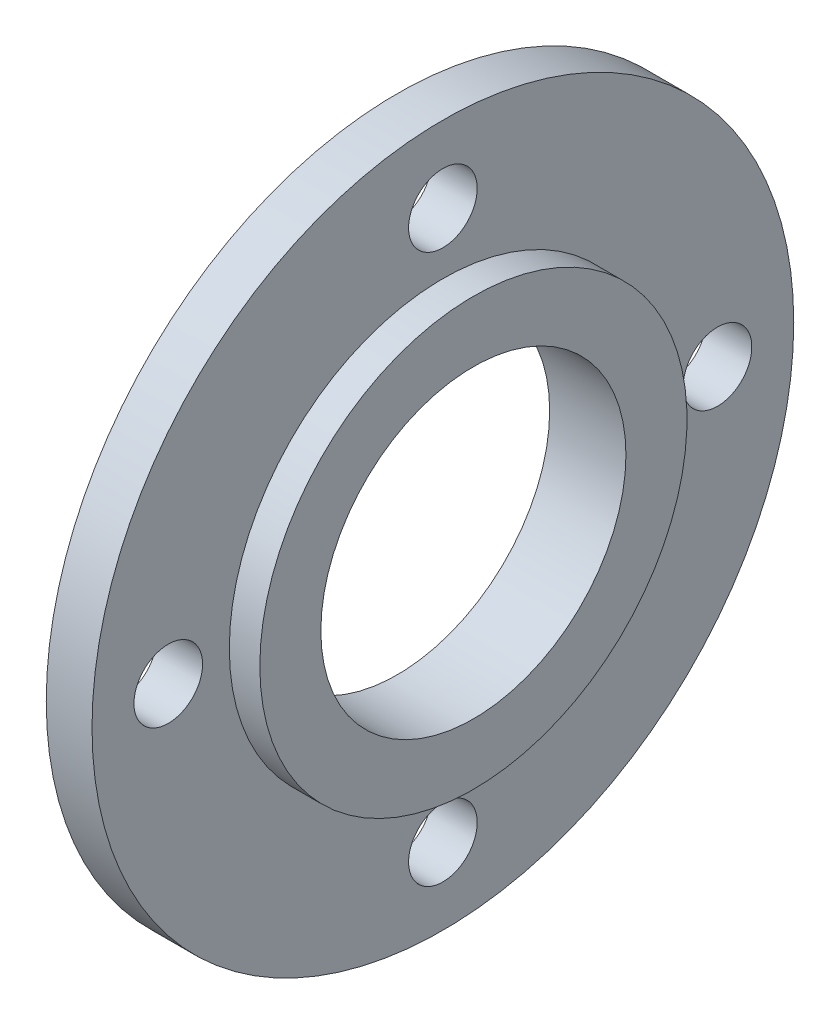
from build123d import *

# Parameters (mm, degrees)
M4_CLEARANCE_HOLE1_D     = 4.5
M4_CLEARANCE_HOLE1_DEPTH = 3
CIRPATTERN1_COUNT        = 4


with BuildPart() as part:
    # Sketch1 → Revolve1 (revolve)
    with BuildSketch(Plane.XY):
        Polygon((0, 10), (5, 10), (5, 14), (3, 14), (3, 23), (0, 23), align=None)
    revolve(axis=Axis((0, 0, 0), (1, 0, 0)))

    # M4 Clearance Hole1
    with Locations(Plane.ZY):
        with Locations((0, 18)):
            m4_clearance_hole1 = Hole(M4_CLEARANCE_HOLE1_D / 2, depth=M4_CLEARANCE_HOLE1_DEPTH)

    # CirPattern1: M4 Clearance Hole1 ×4 about axis
    cirpattern1_axis = Axis((0, 0, 0), (1, 0, 0))
    for i in range(1, CIRPATTERN1_COUNT):
        add(m4_clearance_hole1.rotate(cirpattern1_axis, i * 360 / CIRPATTERN1_COUNT), mode=Mode.SUBTRACT)


solid = part.part
